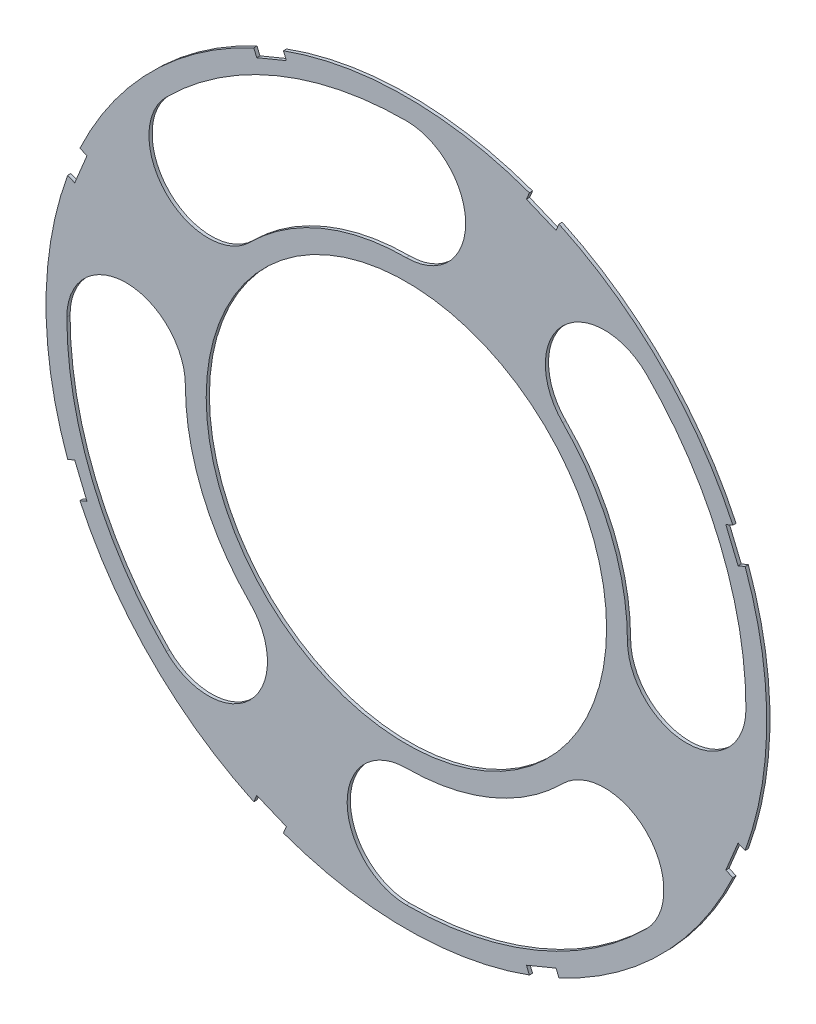
from build123d import *

# Parameters (mm, degrees)
SKETCH4_R           = 28.575
BOSS_EXTRUDE2_DEPTH = 0.254
SKETCH5_R           = 15.875
CUT_EXTRUDE5_DEPTH  = 1.254
CUT_EXTRUDE6_DEPTH  = 1.254
CUT_EXTRUDE11_DEPTH = 1.254


with BuildPart() as part:
    # Sketch4 → Boss-Extrude2 (new body)
    with BuildSketch(Plane.XY):
        Circle(SKETCH4_R)
    extrude(amount=BOSS_EXTRUDE2_DEPTH)

    # Sketch5 → Cut-Extrude5 (cut, through all)
    with BuildSketch(Plane.XY.offset(0.254)):
        Circle(SKETCH5_R)
    extrude(amount=-CUT_EXTRUDE5_DEPTH, mode=Mode.SUBTRACT)

    # Sketch6 → Cut-Extrude6 (cut, through all)
    with BuildSketch(Plane.XY.offset(0.254)):
        with BuildLine():
            ThreePointArc((19.038143, 19.038142953), (12.392753451, 19.038142981), (12.392753462, 12.392753432))
            ThreePointArc((12.392753462, 12.392753432), (16.1919128, 6.706909562), (17.526, -5.71e-07))
            ThreePointArc((17.526, -5.71e-07), (22.224999847, -4.699), (26.924, -8.77e-07))
            ThreePointArc((26.924, -8.77e-07), (24.874532708, 10.303368312), (19.038143, 19.038142953))
        make_face()
        with BuildLine():
            ThreePointArc((19.038142953, -19.038143), (19.038142981, -12.392753451), (12.392753432, -12.392753462))
            ThreePointArc((12.392753432, -12.392753462), (6.706909562, -16.1919128), (-5.71e-07, -17.526))
            ThreePointArc((-5.71e-07, -17.526), (-4.699, -22.224999847), (-8.77e-07, -26.924))
            ThreePointArc((-8.77e-07, -26.924), (10.303368312, -24.874532708), (19.038142953, -19.038143))
        make_face()
        with BuildLine():
            ThreePointArc((-19.038143, -19.038142953), (-12.392753451, -19.038142981), (-12.392753462, -12.392753432))
            ThreePointArc((-12.392753462, -12.392753432), (-16.1919128, -6.706909562), (-17.526, 5.71e-07))
            ThreePointArc((-17.526, 5.71e-07), (-22.224999847, 4.699), (-26.924, 8.77e-07))
            ThreePointArc((-26.924, 8.77e-07), (-24.874532708, -10.303368312), (-19.038143, -19.038142953))
        make_face()
        with BuildLine():
            ThreePointArc((-19.038142953, 19.038143), (-19.038142981, 12.392753451), (-12.392753432, 12.392753462))
            ThreePointArc((-12.392753432, 12.392753462), (-6.706909562, 16.1919128), (5.71e-07, 17.526))
            ThreePointArc((5.71e-07, 17.526), (4.699, 22.224999847), (8.77e-07, 26.924))
            ThreePointArc((8.77e-07, 26.924), (-10.303368312, 24.874532708), (-19.038142953, 19.038143))
        make_face()
    extrude(amount=-CUT_EXTRUDE6_DEPTH, mode=Mode.SUBTRACT)

    # Sketch8 → Cut-Extrude11 (cut, through all)
    with BuildSketch(Plane.XY.offset(0.254)):
        Polygon((27.472529104, 10.004856053), (26.500513186, 12.351510066), (25.327186179, 11.865502107), (26.299202097, 9.518848094), align=None)
        Polygon((-10.004856053, 27.472529104), (-12.351510066, 26.500513186), (-11.865502107, 25.327186179), (-9.518848094, 26.299202097), align=None)
        Polygon((-26.500513186, 12.351510066), (-27.472529104, 10.004856053), (-26.299202097, 9.518848094), (-25.327186179, 11.865502107), align=None)
        Polygon((-27.472529104, -10.004856053), (-26.500513186, -12.351510066), (-25.327186179, -11.865502107), (-26.299202097, -9.518848094), align=None)
        Polygon((-12.351510066, -26.500513186), (-10.004856053, -27.472529104), (-9.518848094, -26.299202097), (-11.865502107, -25.327186179), align=None)
        Polygon((10.004856053, -27.472529104), (12.351510066, -26.500513186), (11.865502107, -25.327186179), (9.518848094, -26.299202097), align=None)
        Polygon((26.500513186, -12.351510066), (27.472529104, -10.004856053), (26.299202097, -9.518848094), (25.327186179, -11.865502107), align=None)
        Polygon((12.351510066, 26.500513186), (10.004856053, 27.472529104), (9.518848094, 26.299202097), (11.865502107, 25.327186179), align=None)
    extrude(amount=-CUT_EXTRUDE11_DEPTH, mode=Mode.SUBTRACT)


solid = part.part
